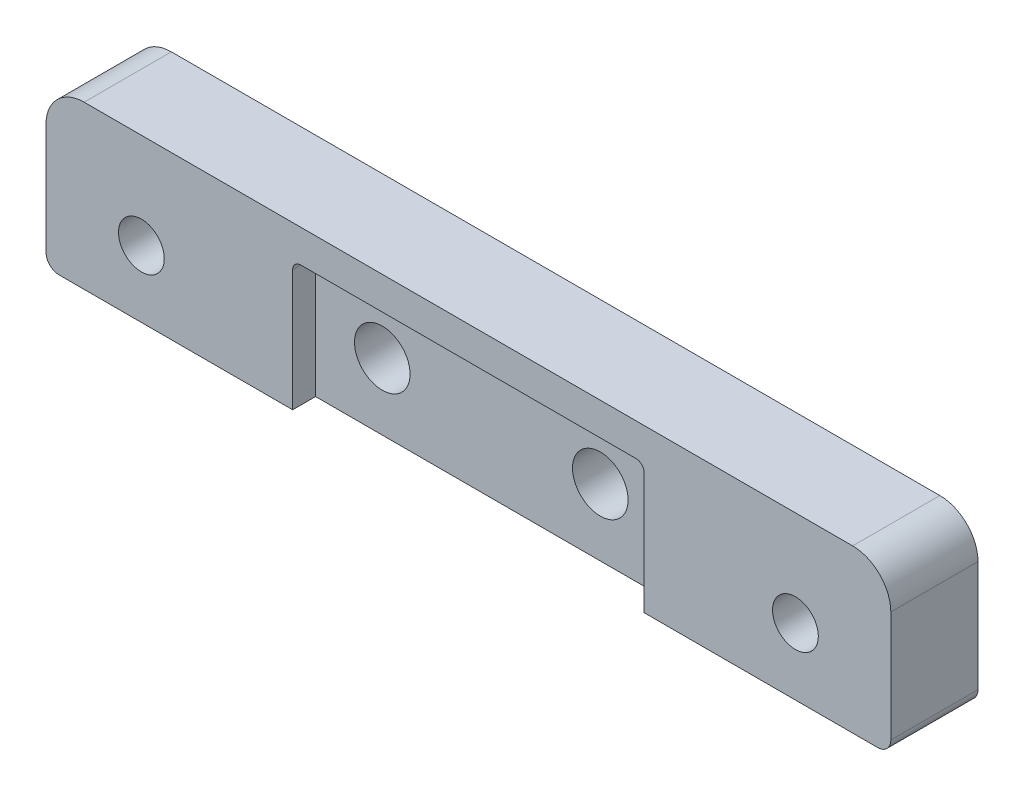
from build123d import *

# Parameters (mm, degrees)
SKETCH1_W             = 77.5
SKETCH1_H             = 14.874
BOSS_EXTRUDE1_DEPTH   = 8
SKETCH2_W             = 32.24
SKETCH2_H             = 11.877
CUT_EXTRUDE1_DEPTH    = 2.1
FILLET1_R             = 3.5
FILLET2_R             = 0.75
SKETCH3_R             = 2.55
CUT_EXTRUDE2_DEPTH    = 6.9
M5X0_8_TAPPED_HOLE1_D = 4.2
FILLET3_R             = 1.2


with BuildPart() as part:
    # Sketch1 → Boss-Extrude1 (new body)
    with BuildSketch(Plane.XY):
        Rectangle(SKETCH1_W, SKETCH1_H)
    extrude(amount=BOSS_EXTRUDE1_DEPTH)

    # Sketch2 → Cut-Extrude1 (cut)
    with BuildSketch(Plane.XY.offset(8)):
        with Locations((0, -1.4985)):
            Rectangle(SKETCH2_W, SKETCH2_H)
    extrude(amount=-CUT_EXTRUDE1_DEPTH, mode=Mode.SUBTRACT)

    # Fillet1
    fillet1_edges = [part.edges().sort_by_distance(p)[0] for p in [
        (-38.75, 7.437, 4),
        (38.75, 7.437, 4),
    ]]
    fillet(fillet1_edges, radius=FILLET1_R)

    # Fillet2
    fillet2_edges = [part.edges().sort_by_distance(p)[0] for p in [
        (-16.12, 4.44, 6.95),
        (16.12, 4.44, 6.95),
    ]]
    fillet(fillet2_edges, radius=FILLET2_R)

    # Sketch3 → Cut-Extrude2 (cut, through all)
    with BuildSketch(Plane.XY.offset(5.9)):
        with Locations((-10, -1.323)):
            Circle(SKETCH3_R)
        with Locations((10, -1.323)):
            Circle(SKETCH3_R)
    extrude(amount=-CUT_EXTRUDE2_DEPTH, mode=Mode.SUBTRACT)

    # M5x0.8 Tapped Hole1 (through all)
    with Locations(Plane.XY.offset(8)):
        with Locations((-30, -1.323), (30, -1.323)):
            Hole(M5X0_8_TAPPED_HOLE1_D / 2)

    # Fillet3
    fillet3_edges = [part.edges().sort_by_distance(p)[0] for p in [
        (38.75, -7.437, 4),
        (-38.75, -7.437, 4),
    ]]
    fillet(fillet3_edges, radius=FILLET3_R)


solid = part.part
